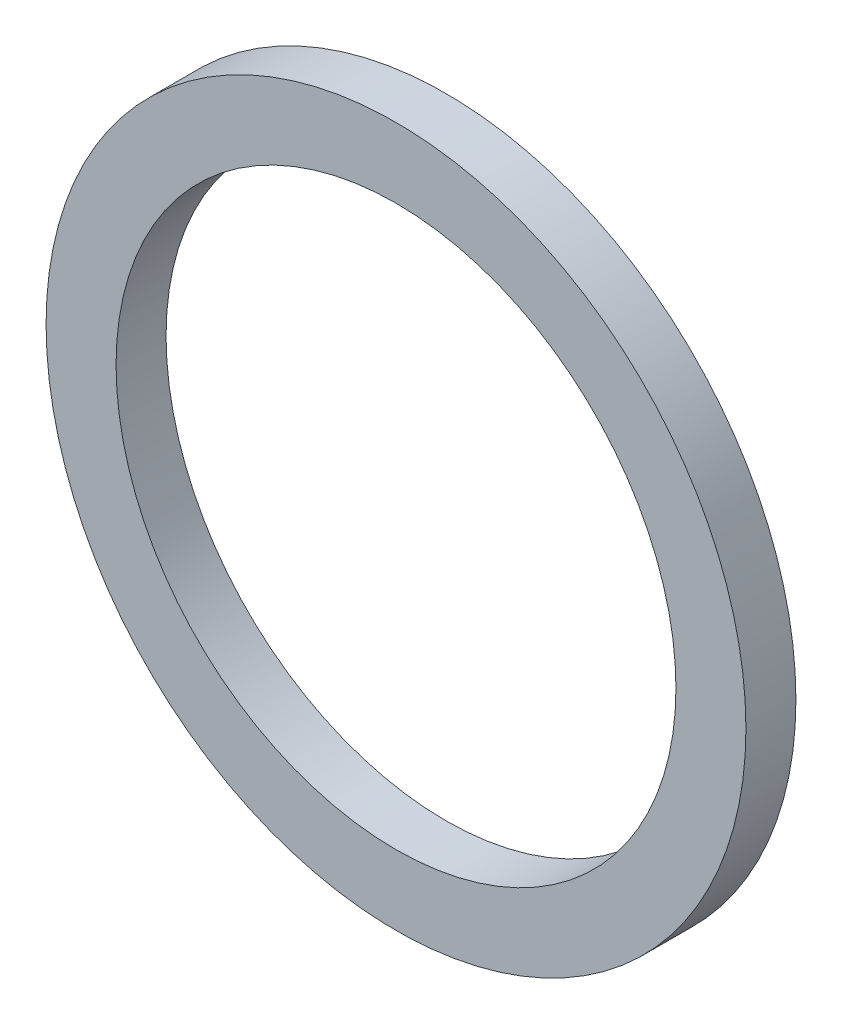
from build123d import *

# Parameters (mm, degrees)
SKETCH1_R           = 7
SKETCH1_R_2         = 5.6
BOSS_EXTRUDE1_DEPTH = 1


with BuildPart() as part:
    # Sketch1 → Boss-Extrude1 (new body)
    with BuildSketch(Plane.XY):
        Circle(SKETCH1_R)
        Circle(SKETCH1_R_2, mode=Mode.SUBTRACT)
    extrude(amount=BOSS_EXTRUDE1_DEPTH)


solid = part.part
